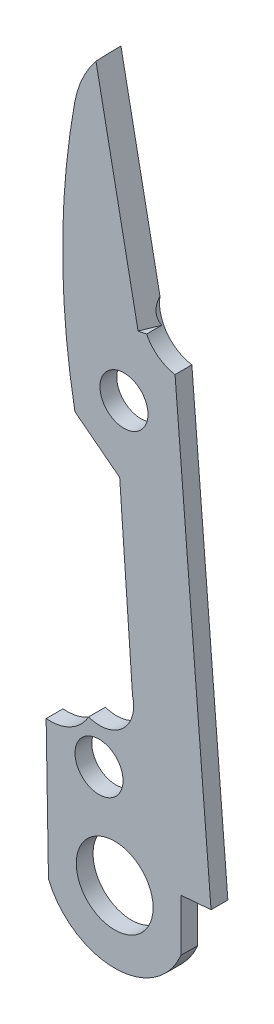
from build123d import *

# Parameters (mm, degrees)
SKETCH1_R           = 1.27
BOSS_EXTRUDE3_DEPTH = 0.889
SKETCH3_R           = 2.032
CUT_EXTRUDE1_DEPTH  = 1.889
CUT_EXTRUDE2_DEPTH  = 12.7


with BuildPart() as part:
    # Sketch1 → Boss-Extrude3 (new body)
    with BuildSketch(Plane.XY):
        with BuildLine():
            Line((54.54799083, 56.616289575), (56.611609417, 46.195015712))
            ThreePointArc((56.611609417, 46.195015712), (56.978037984, 44.693364942), (58.298969551, 43.890641624))
            Line((58.298969551, 43.890641624), (60.203091121, 20.328922191))
            Line((60.203091121, 20.328922191), (58.607476528, 20.19997387))
            Line((58.607476528, 20.19997387), (58.607476528, 17.442451046))
            ThreePointArc((58.607476528, 17.442451046), (55.106284247, 15.101864773), (51.605091967, 17.442451046))
            Line((51.605091967, 17.442451046), (51.481381748, 24.727035664))
            ThreePointArc((51.481381748, 24.727035664), (52.781095987, 24.992110323), (53.724469669, 25.924616503))
            ThreePointArc((53.724469669, 25.924616503), (55.527536206, 26.293339608), (56.052311948, 28.057316955))
            Line((56.052311948, 28.057316955), (55.371384499, 37.710464906))
            Line((55.371384499, 37.710464906), (53.003003997, 39.540899235))
            ThreePointArc((53.003003997, 39.540899235), (52.354767278, 46.624659681), (52.993412204, 53.709291327))
            ThreePointArc((52.993412204, 53.709291327), (53.543144587, 55.284481319), (54.54799083, 56.616289575))
        make_face()
        with Locations((55.596905374, 41.346801264)):
            Circle(SKETCH1_R, mode=Mode.SUBTRACT)
        with Locations((54.27760068, 23.912500713)):
            Circle(SKETCH1_R, mode=Mode.SUBTRACT)
    extrude(amount=BOSS_EXTRUDE3_DEPTH)

    # Sketch3 → Cut-Extrude1 (cut, through all)
    with BuildSketch(Plane.XY.offset(0.889)):
        with Locations((55.106284247, 18.890806819)):
            Circle(SKETCH3_R)
    extrude(amount=-CUT_EXTRUDE1_DEPTH, mode=Mode.SUBTRACT)

    # Sketch4 → Cut-Extrude2 (cut)
    with BuildSketch(Plane(origin=(-8.897590356, 44.932831299, 0), x_dir=(0.980952451, 0.19424801, 0), z_dir=(-0.19424801, 0.980952451, 0))):
        Polygon((64.506586873, 0), (64.506586873, -0.889), (63.993322484, -0.889), align=None)
    extrude(amount=-CUT_EXTRUDE2_DEPTH, mode=Mode.SUBTRACT)


solid = part.part
